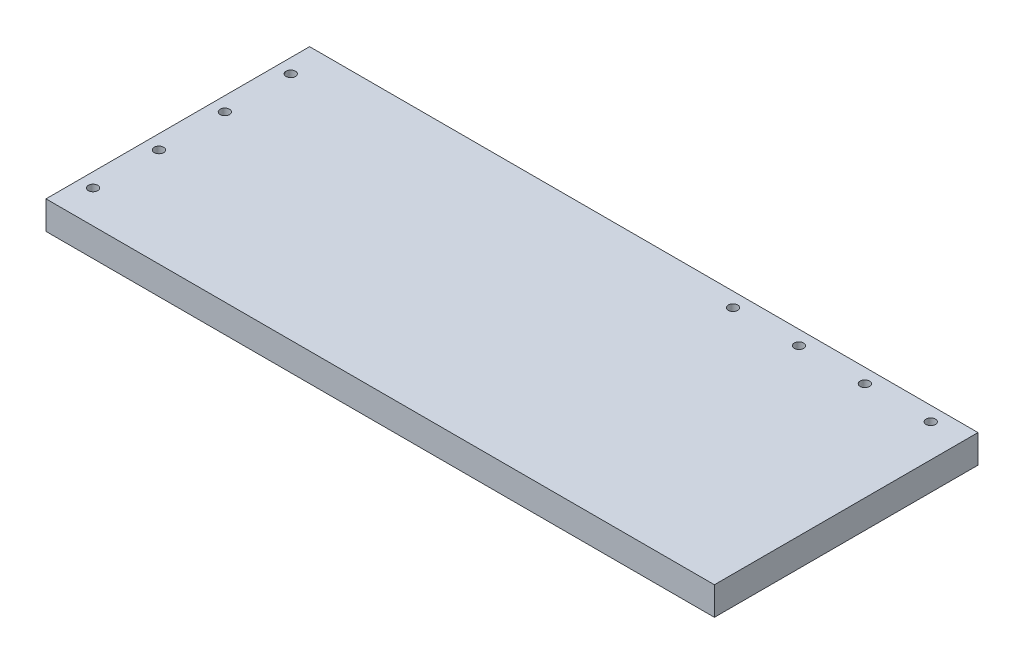
from build123d import *

# Parameters (mm, degrees)
SKETCH1_W                       = 450.85
SKETCH1_H                       = 177.8
BOSS_EXTRUDE1_DEPTH             = 9.525
F_1_4_0_25_DIAMETER_HOLE2_D     = 6.35
F_1_4_0_25_DIAMETER_HOLE2_DEPTH = 25.4
F_1_4_0_25_DIAMETER_HOLE2_TIP   = 1.907732465
F_1_4_0_25_DIAMETER_HOLE3_D     = 6.35
F_1_4_0_25_DIAMETER_HOLE3_DEPTH = 25.4
F_1_4_0_25_DIAMETER_HOLE3_TIP   = 1.907732465


with BuildPart() as part:
    # Sketch1 → Boss-Extrude1 (new body, symmetric)
    with BuildSketch(Plane(origin=(0, 0, 0), x_dir=(1, 0, 0), z_dir=(0, 1, 0))):
        Rectangle(SKETCH1_W, SKETCH1_H)
    extrude(amount=BOSS_EXTRUDE1_DEPTH, both=True)

    # 1/4 (0.25) Diameter Hole2
    with Locations(Plane(origin=(0, 9.525, 0), x_dir=(1, 0, 0), z_dir=(0, 1, 0))):
        with Locations((-215.9, 66.675), (-215.9, 22.225), (-215.9, -22.225), (-215.9, -66.675)):
            Hole(F_1_4_0_25_DIAMETER_HOLE2_D / 2, depth=F_1_4_0_25_DIAMETER_HOLE2_DEPTH)
            with Locations((0, 0, -(F_1_4_0_25_DIAMETER_HOLE2_DEPTH + F_1_4_0_25_DIAMETER_HOLE2_TIP / 2))):  # 118° drill point
                Cone(0, F_1_4_0_25_DIAMETER_HOLE2_D / 2, F_1_4_0_25_DIAMETER_HOLE2_TIP, mode=Mode.SUBTRACT)

    # 1/4 (0.25) Diameter Hole3
    with Locations(Plane(origin=(0, 9.525, 0), x_dir=(1, 0, 0), z_dir=(0, 1, 0))):
        with Locations((203.2, 79.248), (158.75, 79.248), (114.3, 79.248), (69.85, 79.248)):
            Hole(F_1_4_0_25_DIAMETER_HOLE3_D / 2, depth=F_1_4_0_25_DIAMETER_HOLE3_DEPTH)
            with Locations((0, 0, -(F_1_4_0_25_DIAMETER_HOLE3_DEPTH + F_1_4_0_25_DIAMETER_HOLE3_TIP / 2))):  # 118° drill point
                Cone(0, F_1_4_0_25_DIAMETER_HOLE3_D / 2, F_1_4_0_25_DIAMETER_HOLE3_TIP, mode=Mode.SUBTRACT)


solid = part.part
